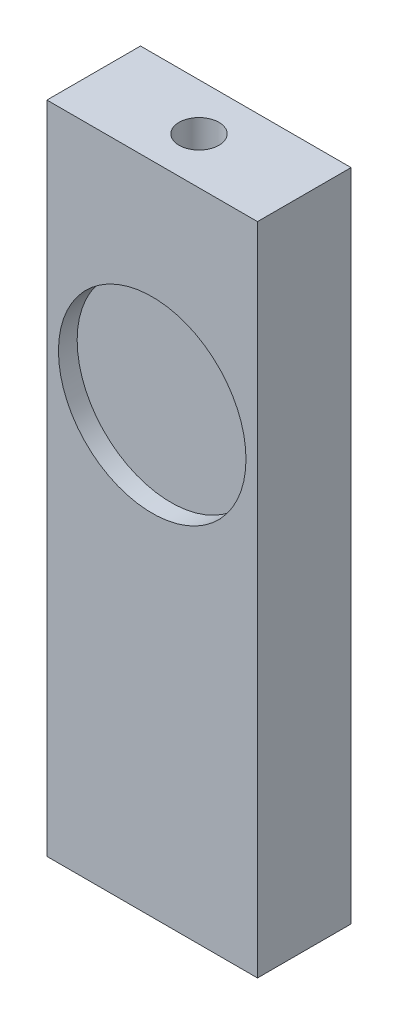
from build123d import *

# Parameters (mm, degrees)
SKETCH1_W                           = 14.2875
SKETCH1_H                           = 6.35
EXTRUDE1_DEPTH                      = 44.45
SKETCH6_R                           = 6.3627
CUT_EXTRUDE2_DEPTH                  = 1.27
F_6_32_TAPPED_HOLE1_D               = 2.7051
F_6_32_TAPPED_HOLE1_DEPTH           = 9.398
F_6_32_TAPPED_HOLE1_TIP             = 0.81269403
F_6_32_TAPPED_HOLE1_ON_FACE_2_D     = 2.7051
F_6_32_TAPPED_HOLE1_ON_FACE_2_DEPTH = 9.398
F_6_32_TAPPED_HOLE1_ON_FACE_2_TIP   = 0.81269403


with BuildPart() as part:
    # Sketch1 → Extrude1 (new body)
    with BuildSketch(Plane(origin=(0, 0, 0), x_dir=(1, 0, 0), z_dir=(0, 1, 0))):
        with Locations((-45.973078165, 33.616731266)):
            Rectangle(SKETCH1_W, SKETCH1_H)
    extrude(amount=EXTRUDE1_DEPTH)

    # Sketch6 → Cut-Extrude2 (cut)
    with BuildSketch(Plane.XY.offset(-30.441731266)):
        with Locations((-45.973078165, 30.099)):
            Circle(SKETCH6_R)
    extrude(amount=-CUT_EXTRUDE2_DEPTH, mode=Mode.SUBTRACT)

    # #6-32 Tapped Hole1
    with Locations(Plane(origin=(-45.973078165, 44.45, -33.616731266), x_dir=(0, 0, 1), z_dir=(0, 1, 0))):
        with Locations((0, 0)):
            Hole(F_6_32_TAPPED_HOLE1_D / 2, depth=F_6_32_TAPPED_HOLE1_DEPTH)
            with Locations((0, 0, -(F_6_32_TAPPED_HOLE1_DEPTH + F_6_32_TAPPED_HOLE1_TIP / 2))):  # 118° drill point
                Cone(0, F_6_32_TAPPED_HOLE1_D / 2, F_6_32_TAPPED_HOLE1_TIP, mode=Mode.SUBTRACT)

    # #6-32 Tapped Hole1 on face 2
    with Locations(Plane(origin=(-45.973078165, 0, -33.616731266), x_dir=(0, 0, -1), z_dir=(0, -1, 0))):
        with Locations((0, 0)):
            Hole(F_6_32_TAPPED_HOLE1_ON_FACE_2_D / 2, depth=F_6_32_TAPPED_HOLE1_ON_FACE_2_DEPTH)
            with Locations((0, 0, -(F_6_32_TAPPED_HOLE1_ON_FACE_2_DEPTH + F_6_32_TAPPED_HOLE1_ON_FACE_2_TIP / 2))):  # 118° drill point
                Cone(0, F_6_32_TAPPED_HOLE1_ON_FACE_2_D / 2, F_6_32_TAPPED_HOLE1_ON_FACE_2_TIP, mode=Mode.SUBTRACT)


solid = part.part
